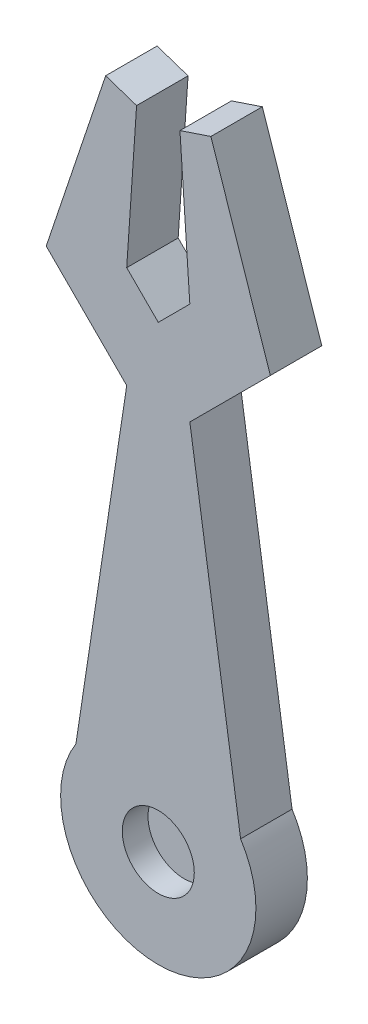
from build123d import *

# Parameters (mm, degrees)
BOSS_EXTRUDE1_DEPTH = 10
SKETCH2_R           = 7
CUT_EXTRUDE1_DEPTH  = 5


with BuildPart() as part:
    # Sketch1 → Boss-Extrude1 (new body)
    with BuildSketch(Plane.XY):
        with BuildLine():
            Line((0, 0), (-15.642172524, 15.642172524))
            Line((-15.642172524, 15.642172524), (-4.089456869, 50.095846645))
            Line((-4.089456869, 50.095846645), (1.922169026, 48.080078912))
            Line((1.922169026, 48.080078912), (0, 19.833865815))
            Line((0, 19.833865815), (6.134185304, 13.699680511))
            Line((6.134185304, 13.699680511), (12.268370607, 19.833865815))
            Line((12.268370607, 19.833865815), (10.346201581, 48.080078912))
            Line((10.346201581, 48.080078912), (16.357827476, 50.095846645))
            Line((16.357827476, 50.095846645), (27.910543131, 15.642172524))
            Line((27.910543131, 15.642172524), (12.268370607, 0))
            Line((12.268370607, 0), (22.134185304, -65.230001967))
            ThreePointArc((22.134185304, -65.230001967), (6.134185304, -94.406570423), (-9.865814696, -65.230001967))
            Line((-9.865814696, -65.230001967), (0, 0))
        make_face()
    extrude(amount=BOSS_EXTRUDE1_DEPTH)

    # Sketch2 → Cut-Extrude1 (cut)
    with BuildSketch(Plane.XY.offset(10)):
        with Locations((6.134185304, -75.431204137)):
            Circle(SKETCH2_R)
    extrude(amount=-CUT_EXTRUDE1_DEPTH, mode=Mode.SUBTRACT)


solid = part.part
